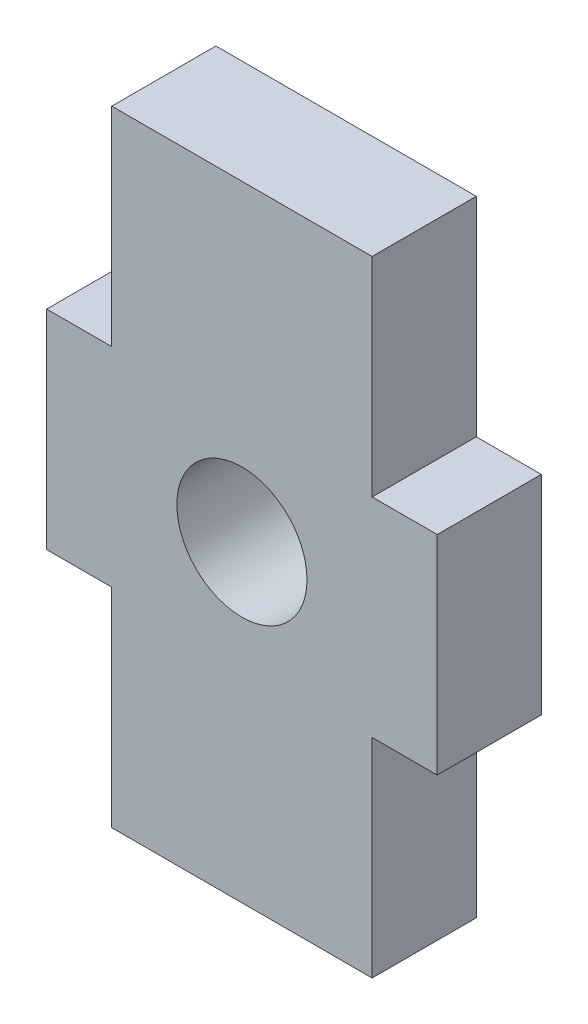
from build123d import *

# Parameters (mm, degrees)
SKETCH1_R           = 1.25
BOSS_EXTRUDE1_DEPTH = 2


with BuildPart() as part:
    # Sketch1 → Boss-Extrude1 (new body)
    with BuildSketch(Plane.XY):
        Polygon((1952.176808721, 1466.884115951), (1957.176808721, 1466.884115951), (1957.176808721, 1462.884115951), (1958.426808721, 1462.884115951), (1958.426808721, 1458.884115951), (1957.176808721, 1458.884115951), (1957.176808721, 1454.884115951), (1952.176808721, 1454.884115951), (1952.176808721, 1458.884115951), (1950.926808721, 1458.884115951), (1950.926808721, 1462.884115951), (1952.176808721, 1462.884115951), align=None)
        with Locations((1954.676808721, 1460.884115951)):
            Circle(SKETCH1_R, mode=Mode.SUBTRACT)
    extrude(amount=BOSS_EXTRUDE1_DEPTH)


solid = part.part
